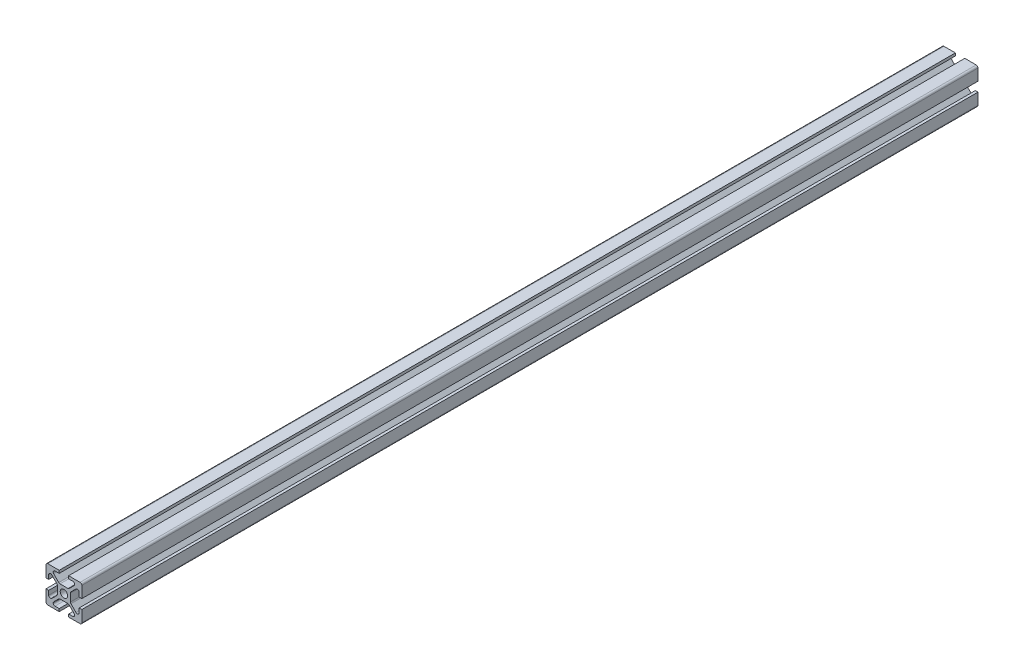
from build123d import *

# Parameters (mm, degrees)
SKETCH1_R           = 2.06
BOSS_EXTRUDE1_DEPTH = 250
CUT_EXTRUDE1_DEPTH  = 501
CIRPATTERN1_COUNT   = 4


with BuildPart() as part:
    # Sketch1 → Boss-Extrude1 (new body, symmetric)
    with BuildSketch(Plane.XY):
        with BuildLine():
            Line((-9, 10), (9, 10))
            ThreePointArc((9, 10), (9.707106781, 9.707106781), (10, 9))
            Line((10, 9), (10, -9))
            ThreePointArc((10, -9), (9.707106781, -9.707106781), (9, -10))
            Line((9, -10), (-9, -10))
            ThreePointArc((-9, -10), (-9.707106781, -9.707106781), (-10, -9))
            Line((-10, -9), (-10, 9))
            ThreePointArc((-10, 9), (-9.707106781, 9.707106781), (-9, 10))
        make_face()
        Circle(SKETCH1_R, mode=Mode.SUBTRACT)
    extrude(amount=BOSS_EXTRUDE1_DEPTH, both=True)

    # Sketch2 → Cut-Extrude1 (cut, through all)
    with BuildSketch(Plane(origin=(0, 0, -250), x_dir=(-1, 0, 0), z_dir=(0, 0, -1))):
        with BuildLine():
            Line((-10, 2.63), (-8.5, 2.63))
            Line((-8.5, 2.63), (-8.5, 4.995))
            ThreePointArc((-8.5, 4.995), (-8.207106781, 5.702106781), (-7.5, 5.995))
            Line((-7.5, 5.995), (-7.469873734, 5.995))
            ThreePointArc((-7.469873734, 5.995), (-7.087190302, 5.918879533), (-6.762766953, 5.702106781))
            Line((-6.762766953, 5.702106781), (-3.947893219, 2.887233047))
            ThreePointArc((-3.947893219, 2.887233047), (-3.731120467, 2.562809698), (-3.655, 2.180126266))
            Line((-3.655, 2.180126266), (-3.655, -2.180126266))
            ThreePointArc((-3.655, -2.180126266), (-3.731120467, -2.562809698), (-3.947893219, -2.887233047))
            Line((-3.947893219, -2.887233047), (-6.762766953, -5.702106781))
            ThreePointArc((-6.762766953, -5.702106781), (-7.087190302, -5.918879533), (-7.469873734, -5.995))
            Line((-7.469873734, -5.995), (-7.5, -5.995))
            ThreePointArc((-7.5, -5.995), (-8.207106781, -5.702106781), (-8.5, -4.995))
            Line((-8.5, -4.995), (-8.5, -2.63))
            Line((-8.5, -2.63), (-10, -2.63))
            Line((-10, -2.63), (-10, 2.63))
        make_face()
    cut_extrude1 = extrude(amount=-CUT_EXTRUDE1_DEPTH, mode=Mode.SUBTRACT)

    # CirPattern1: Cut-Extrude1 ×4 about axis
    cirpattern1_axis = Axis((0, 0, 0), (0, 0, 1))
    for i in range(1, CIRPATTERN1_COUNT):
        add(cut_extrude1.rotate(cirpattern1_axis, i * 360 / CIRPATTERN1_COUNT), mode=Mode.SUBTRACT)


solid = part.part
